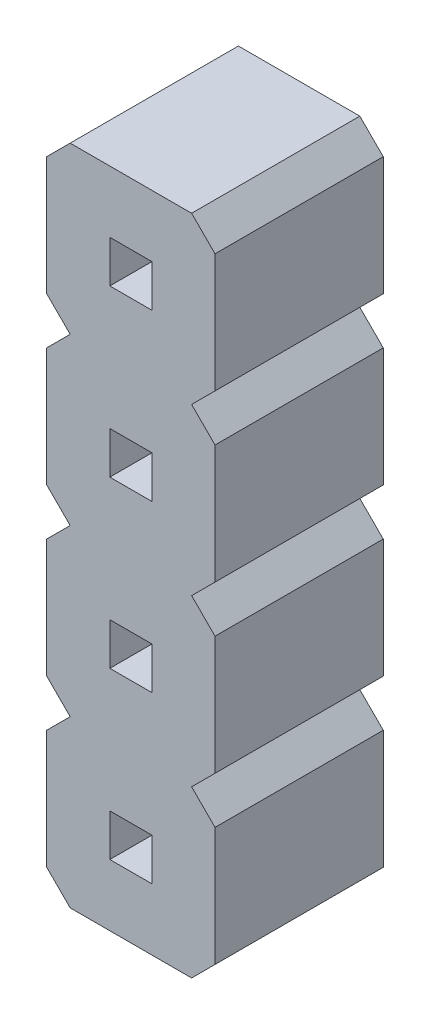
from build123d import *

# Parameters (mm, degrees)
PIN_DRAWING_W       = 0.636
PIN_DRAWING_H       = 0.636
BOSS_EXTRUDE1_DEPTH = 2.54


with BuildPart() as part:
    # pin_drawing → Boss-Extrude1 (new body)
    with BuildSketch(Plane.XY):
        Polygon((0, 2.146446609), (0, 0.353553391), (0.353553391, 0), (0, -0.353553391), (0, -2.146446609), (0.353553391, -2.5), (2.187446609, -2.5), (2.541, -2.146446609), (2.541, -0.353553391), (2.187446609, 0), (2.541, 0.353553391), (2.541, 2.146446609), (2.187446609, 2.5), (2.541, 2.853553391), (2.541, 4.646446609), (2.187446609, 5), (2.541, 5.353553391), (2.541, 7.146446609), (2.187446609, 7.5), (0.353553391, 7.5), (0, 7.146446609), (0, 5.353553391), (0.353553391, 5), (0, 4.646446609), (0, 2.853553391), (0.353553391, 2.5), align=None)
        with Locations((1.2705, -1.25)):
            Rectangle(PIN_DRAWING_W, PIN_DRAWING_H, mode=Mode.SUBTRACT)
        with Locations((1.2705, 1.25)):
            Rectangle(PIN_DRAWING_W, PIN_DRAWING_H, mode=Mode.SUBTRACT)
        with Locations((1.2705, 3.75)):
            Rectangle(PIN_DRAWING_W, PIN_DRAWING_H, mode=Mode.SUBTRACT)
        with Locations((1.2705, 6.25)):
            Rectangle(PIN_DRAWING_W, PIN_DRAWING_H, mode=Mode.SUBTRACT)
    extrude(amount=BOSS_EXTRUDE1_DEPTH)


solid = part.part
